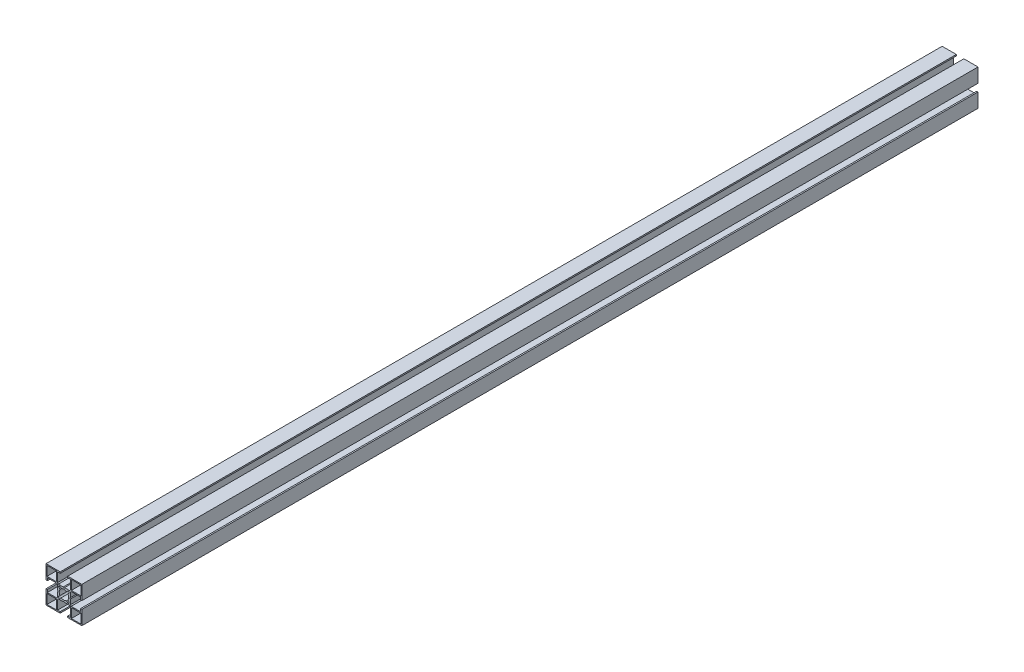
from build123d import *

# Parameters (mm, degrees)
SKETCH_1_W      = 10.6
SKETCH_1_H      = 10.6
EXTRUDE_1_DEPTH = 1000


with BuildPart() as part:
    # Эскиз1 → Бобышка-Вытянуть1 (new body)
    with BuildSketch(Plane.XY):
        Polygon((-20, 7.15), (-20, 20), (-7.15, 20), (-4.2, 20), (-4.2, 18.5), (-7.15, 18.5), (-7.15, 8.15), (-6.15, 7.15), (-0.7, 7.15), (0, 6.45), (0.7, 7.15), (6.15, 7.15), (7.15, 8.15), (7.15, 18.5), (4.2, 18.5), (4.2, 20), (7.15, 20), (20, 20), (20, 7.15), (20, 4.2), (18.5, 4.2), (18.5, 7.15), (8.15, 7.15), (7.15, 6.15), (7.15, 0.7), (6.45, 0), (7.15, -0.7), (7.15, -6.15), (8.15, -7.15), (18.5, -7.15), (18.5, -4.2), (20, -4.2), (20, -7.15), (20, -20), (7.15, -20), (4.2, -20), (4.2, -18.5), (7.15, -18.5), (7.15, -8.15), (6.15, -7.15), (0.7, -7.15), (0, -6.45), (-0.7, -7.15), (-6.15, -7.15), (-7.15, -8.15), (-7.15, -18.5), (-4.2, -18.5), (-4.2, -20), (-7.15, -20), (-20, -20), (-20, -7.15), (-20, -4.2), (-18.5, -4.2), (-18.5, -7.15), (-8.15, -7.15), (-7.15, -6.15), (-7.15, -0.7), (-6.45, 0), (-7.15, 0.7), (-7.15, 6.15), (-8.15, 7.15), (-18.5, 7.15), (-18.5, 4.2), (-20, 4.2), align=None)
        with Locations((13.6, 13.6)):
            Rectangle(SKETCH_1_W, SKETCH_1_H, mode=Mode.SUBTRACT)
        with Locations((-13.6, 13.6)):
            Rectangle(SKETCH_1_W, SKETCH_1_H, mode=Mode.SUBTRACT)
        with Locations((13.6, -13.6)):
            Rectangle(SKETCH_1_W, SKETCH_1_H, mode=Mode.SUBTRACT)
        with Locations((-13.6, -13.6)):
            Rectangle(SKETCH_1_W, SKETCH_1_H, mode=Mode.SUBTRACT)
        with BuildLine():
            Line((4.242640687, 5.656854249), (2.937238153, 4.351451715))
            ThreePointArc((2.937238153, 4.351451715), (0, 5.25), (-2.937238153, 4.351451715))
            Line((-2.937238153, 4.351451715), (-4.242640687, 5.656854249))
            ThreePointArc((-4.242640687, 5.656854249), (-5.656854249, 5.656854249), (-5.656854249, 4.242640687))
            Line((-5.656854249, 4.242640687), (-4.351451715, 2.937238153))
            ThreePointArc((-4.351451715, 2.937238153), (-5.25, 0), (-4.351451715, -2.937238153))
            Line((-4.351451715, -2.937238153), (-5.656854249, -4.242640687))
            ThreePointArc((-5.656854249, -4.242640687), (-5.656854249, -5.656854249), (-4.242640687, -5.656854249))
            Line((-4.242640687, -5.656854249), (-2.937238153, -4.351451715))
            ThreePointArc((-2.937238153, -4.351451715), (0, -5.25), (2.937238153, -4.351451715))
            Line((2.937238153, -4.351451715), (4.242640687, -5.656854249))
            ThreePointArc((4.242640687, -5.656854249), (5.656854249, -5.656854249), (5.656854249, -4.242640687))
            Line((5.656854249, -4.242640687), (4.351451715, -2.937238153))
            ThreePointArc((4.351451715, -2.937238153), (5.25, 0), (4.351451715, 2.937238153))
            Line((4.351451715, 2.937238153), (5.656854249, 4.242640687))
            ThreePointArc((5.656854249, 4.242640687), (5.656854249, 5.656854249), (4.242640687, 5.656854249))
        make_face(mode=Mode.SUBTRACT)
    extrude(amount=EXTRUDE_1_DEPTH)


solid = part.part
